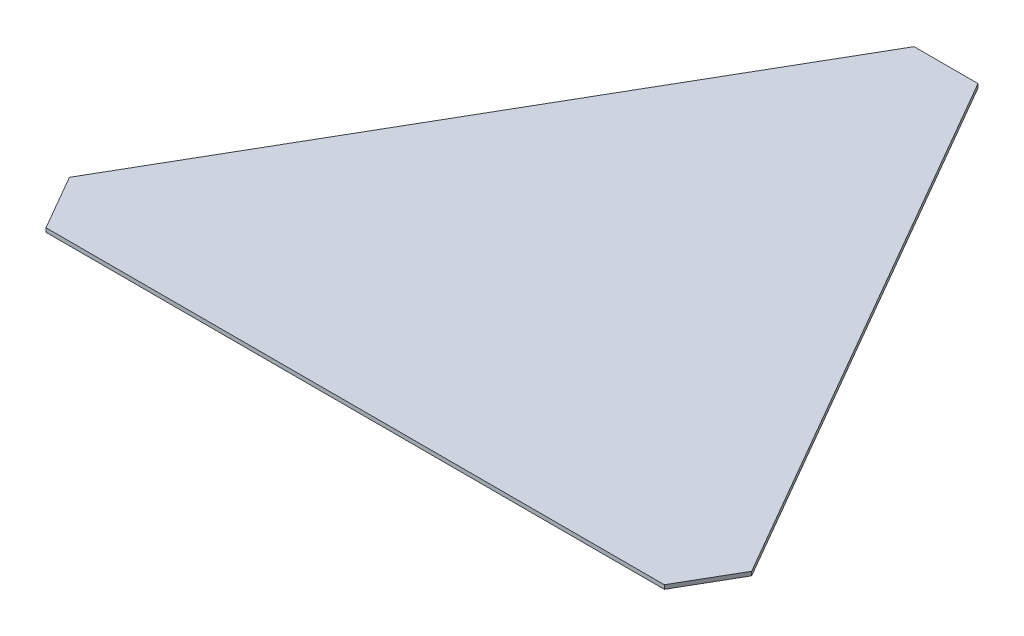
from build123d import *

# Parameters (mm, degrees)
SALIENTE_EXTRUIR1_DEPTH = 5


with BuildPart() as part:
    # Croquis1 → Saliente-Extruir1 (new body)
    with BuildSketch(Plane(origin=(0, 0, 0), x_dir=(1, 0, 0), z_dir=(0, 1, 0))):
        Polygon((-40, 470), (40, 470), (427.031939779, -200.358983849), (387.031939779, -269.641016151), (-387.031939779, -269.641016151), (-427.031939779, -200.358983849), align=None)
    extrude(amount=SALIENTE_EXTRUIR1_DEPTH)


solid = part.part
